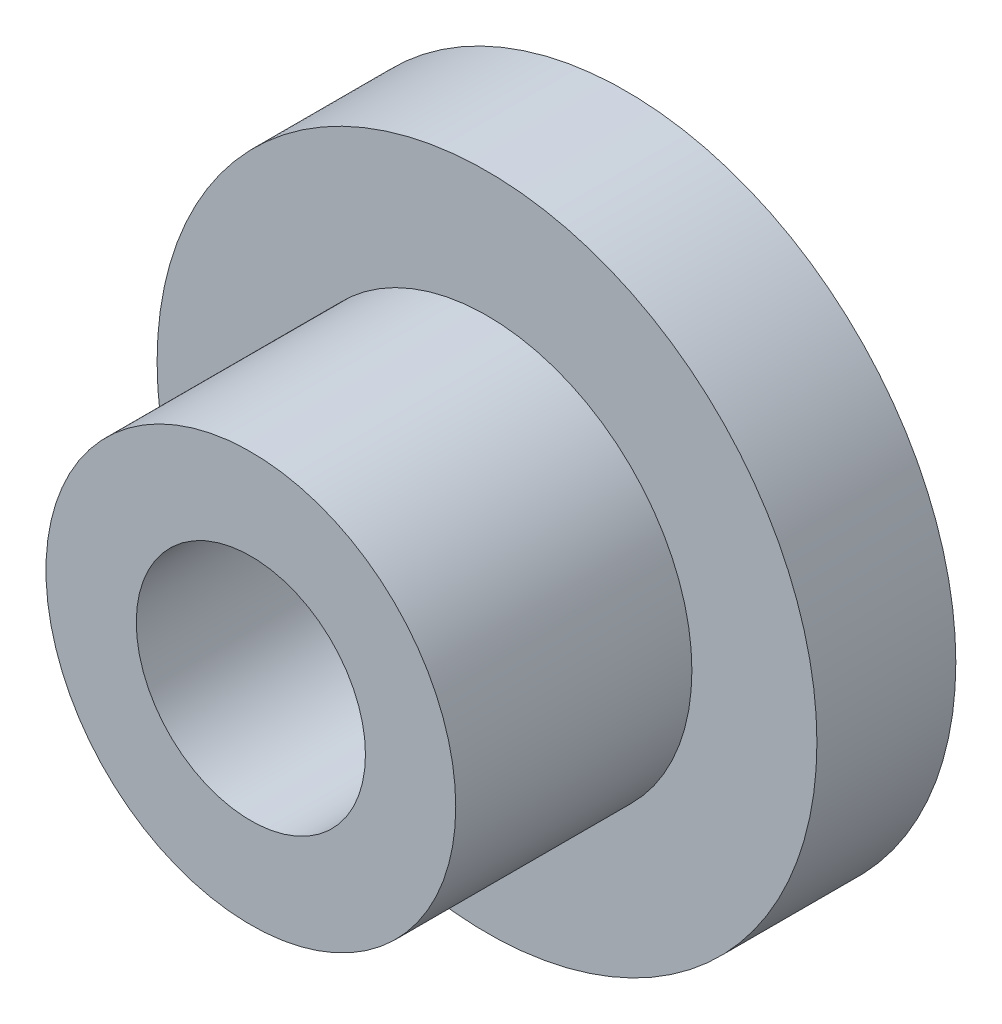
from build123d import *

# Parameters (mm, degrees)
M4X0_7_TAPPED_HOLE1_D     = 3.3
M4X0_7_TAPPED_HOLE1_DEPTH = 5.4


with BuildPart() as part:
    # Sketch1 → Revolve1 (revolve)
    with BuildSketch(Plane(origin=(0, 0, 0), x_dir=(0, 0, -1), z_dir=(1, 0, 0)), mode=Mode.PRIVATE) as revolve1_sk:
        Polygon((0, 0), (0, 4.75), (-2, 4.75), (-2, 2.95), (-5.4, 2.95), (-5.4, 0), align=None)
    revolve(revolve1_sk.sketch.rotate(Axis((0, 0, 90.144320428), (0, 0, -1)), 90), axis=Axis((0, 0, 90.144320428), (0, 0, -1)))  # turned: the seam where the file's is

    # M4x0.7 Tapped Hole1
    with Locations(Plane(origin=(-1.585228974, 0.882737227, 5.4), x_dir=(1, 0, 0), z_dir=(0, 0, 1))):
        with Locations((1.585228974, -0.882737227)):
            Hole(M4X0_7_TAPPED_HOLE1_D / 2, depth=M4X0_7_TAPPED_HOLE1_DEPTH)


solid = part.part
